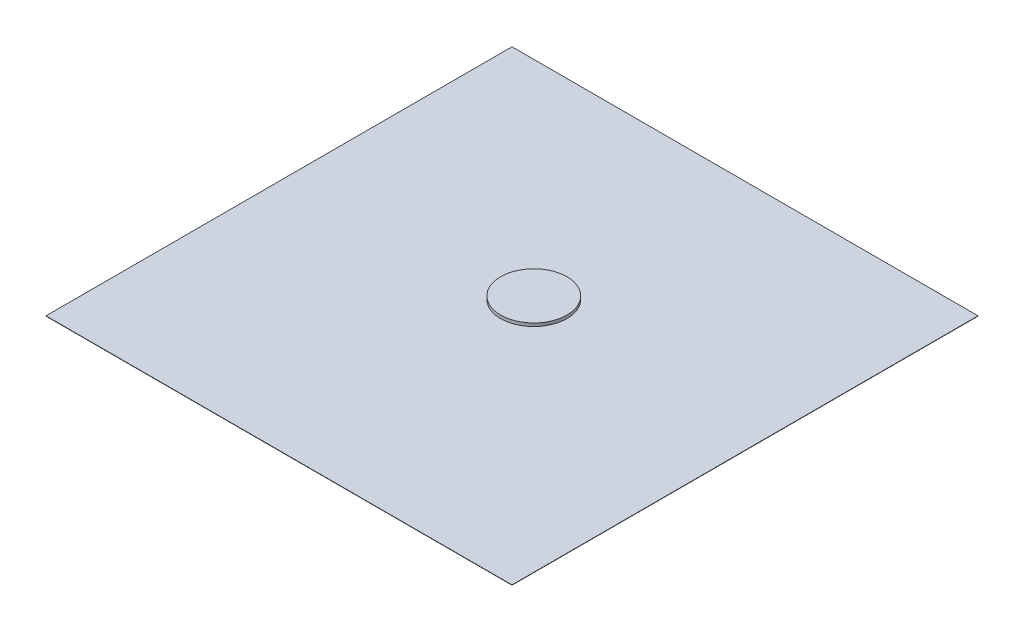
from build123d import *

# Parameters (mm, degrees)
SKETCH1_W           = 1500
SKETCH1_H           = 1500
BOSS_EXTRUDE1_DEPTH = 1
SKETCH2_R           = 106.81441709
BOSS_EXTRUDE2_DEPTH = 10


with BuildPart() as part:
    # Sketch1 → Boss-Extrude1 (new body)
    with BuildSketch(Plane(origin=(0, 0, 0), x_dir=(1, 0, 0), z_dir=(0, 1, 0))):
        with Locations((750, 750)):
            Rectangle(SKETCH1_W, SKETCH1_H)
    extrude(amount=BOSS_EXTRUDE1_DEPTH)

    # Sketch2 → Boss-Extrude2 (add)
    with BuildSketch(Plane(origin=(0, 1, 0), x_dir=(1, 0, 0), z_dir=(0, 1, 0))):
        with Locations((739.527998324, 830.634412902)):
            Circle(SKETCH2_R)
    extrude(amount=BOSS_EXTRUDE2_DEPTH)


solid = part.part
